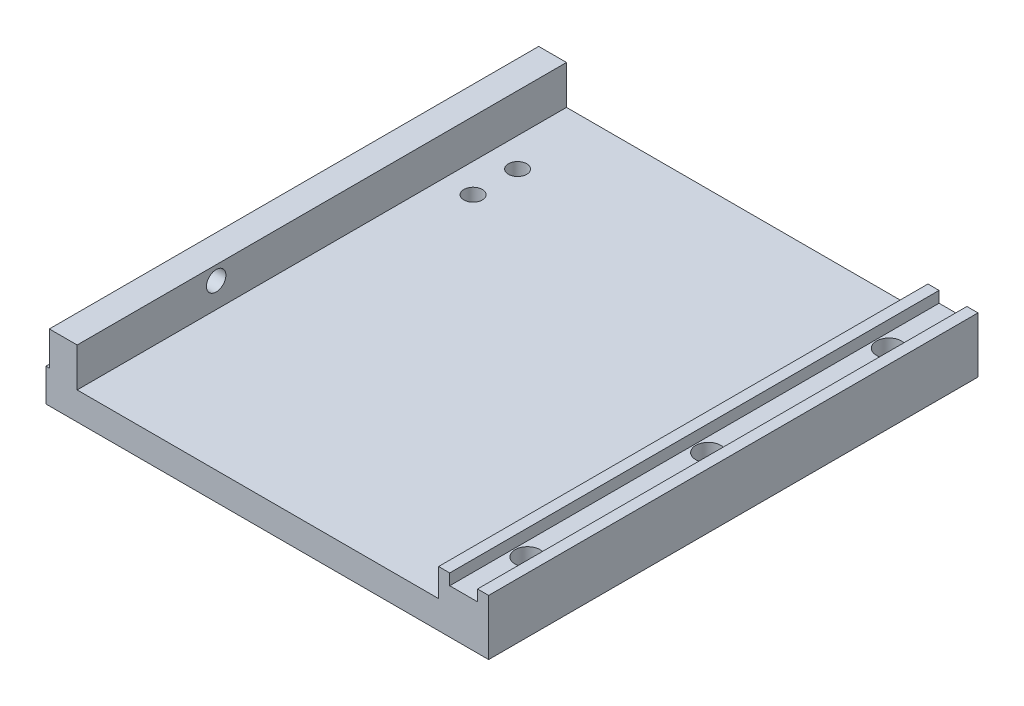
from build123d import *

# Parameters (mm, degrees)
EXTRUDE_1_DEPTH              = 88
HOLE_WIZARD_M4_1_D           = 4.5
HOLE_WIZARD_M4_1_CBORE_D     = 8
HOLE_WIZARD_M4_1_CBORE_DEPTH = 4.4
HOLE_WIZARD_M4_1_2_D         = 3.3
HOLE_WIZARD_M3_1_D           = 2.5
HOLE_WIZARD_M3_1_DEPTH       = 9.5
HOLE_WIZARD_M3_1_TIP         = 0.751075774
SKETCH_8_R                   = 1.75
CUT_EXTRUDE_1_DEPTH          = 5


with BuildPart() as part:
    # 草图1 → 凸台-拉伸1 (new body)
    with BuildSketch(Plane.XY):
        Polygon((-9, 10), (-9, 5), (-74, 5), (-74, 12), (-79, 12), (-79, 5.9), (-79.6, 5.9), (-79.6, 0), (0, 0), (0, 10), (-2, 10), (-2, 8), (-7, 8), (-7, 10), align=None)
    extrude(amount=EXTRUDE_1_DEPTH)

    # Hole Wizard M4 _1 (through all)
    with Locations(Plane(origin=(0, 0, 0), x_dir=(-1, 0, 0), z_dir=(0, -1, 0))):
        with Locations((4.5, -11.5), (4.5, -44), (4.5, -76.5)):
            CounterBoreHole(HOLE_WIZARD_M4_1_D / 2, HOLE_WIZARD_M4_1_CBORE_D / 2, HOLE_WIZARD_M4_1_CBORE_DEPTH)

    # Hole Wizard M4 _1 2 (through all)
    with Locations(Plane(origin=(0, 0, 0), x_dir=(-1, 0, 0), z_dir=(0, -1, 0))):
        with Locations((68.8, -14), (68.8, -22)):
            Hole(HOLE_WIZARD_M4_1_2_D / 2)

    # M3 螺纹孔1
    with Locations(Plane.ZY.offset(79.6)):
        with Locations((11.5, 3), (44, 3), (76.5, 3)):
            Hole(HOLE_WIZARD_M3_1_D / 2, depth=HOLE_WIZARD_M3_1_DEPTH)
            with Locations((0, 0, -(HOLE_WIZARD_M3_1_DEPTH + HOLE_WIZARD_M3_1_TIP / 2))):  # 118° drill point
                Cone(0, HOLE_WIZARD_M3_1_D / 2, HOLE_WIZARD_M3_1_TIP, mode=Mode.SUBTRACT)

    # 草图8 → 切除-拉伸1 (cut)
    with BuildSketch(Plane.ZY.offset(79)):
        with Locations((63, 9.5)):
            Circle(SKETCH_8_R)
    extrude(amount=-CUT_EXTRUDE_1_DEPTH, mode=Mode.SUBTRACT)


solid = part.part
